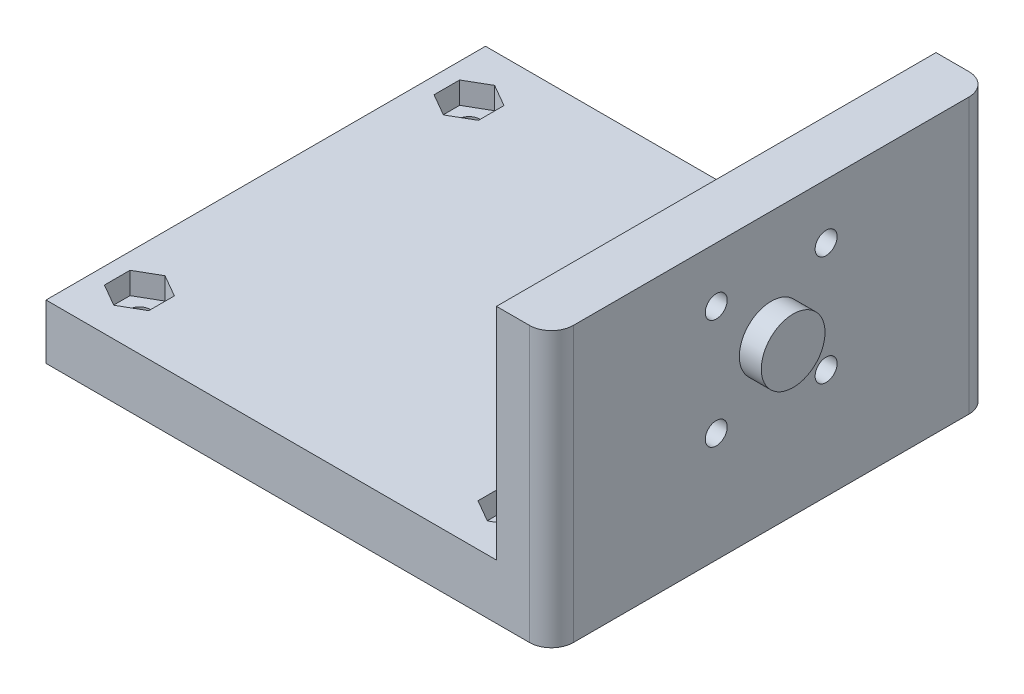
from build123d import *

# Parameters (mm, degrees)
ESQUISSE1_W             = 5
ESQUISSE1_H             = 40
BOSS_EXTRU_1_DEPTH      = 25
ESQUISSE2_W             = 40
ESQUISSE2_H             = 5
BOSS_EXTRU_2_DEPTH      = 41
CONG_1_R                = 2
ENL_V_MAT_EXTRU_1_REACH = 48
ESQUISSE4_R             = 1
ESQUISSE5_R             = 2.9
BOSS_EXTRU_3_DEPTH      = 2
ENL_V_MAT_EXTRU_3_DEPTH = 3
ESQUISSE9_R             = 1
ENL_V_MAT_EXTRU_5_DEPTH = 6
ENL_V_MAT_EXTRU_4_DEPTH = 2


with BuildPart() as part:
    # Esquisse1 → Boss.-Extru.1 (new body)
    with BuildSketch(Plane(origin=(0, 0, 0), x_dir=(1, 0, 0), z_dir=(0, 1, 0))):
        with Locations((-2.5, 0)):
            Rectangle(ESQUISSE1_W, ESQUISSE1_H)
    extrude(amount=-BOSS_EXTRU_1_DEPTH)

    # Esquisse2 → Boss.-Extru.2 (add)
    with BuildSketch(Plane.ZY.offset(5)):
        with Locations((0, -22.5)):
            Rectangle(ESQUISSE2_W, ESQUISSE2_H)
    extrude(amount=BOSS_EXTRU_2_DEPTH)

    # Congé1
    cong_1_edges = [part.edges().sort_by_distance(p)[0] for p in [
        (0, -12.5, 20),
        (0, -12.5, -20),
    ]]
    fillet(cong_1_edges, radius=CONG_1_R)

    # Esquisse4 → Enlèv. mat.-Extru.1 (cut, up to next)
    with BuildSketch(Plane(origin=(0, 0, 0), x_dir=(0, 0, -1), z_dir=(1, 0, 0)), mode=Mode.PRIVATE) as enl_v_mat_extru_1_sk1:
        with Locations((-5, -5)):
            Circle(ESQUISSE4_R)
    enl_v_mat_extru_1_tool1 = extrude(enl_v_mat_extru_1_sk1.sketch, amount=-ENL_V_MAT_EXTRU_1_REACH, mode=Mode.PRIVATE) & part.part
    add(enl_v_mat_extru_1_tool1.solids().sort_by_distance((0, -5, 5))[0], mode=Mode.SUBTRACT)
    # Esquisse4 → Enlèv. mat.-Extru.1 (cut, up to next)
    with BuildSketch(Plane(origin=(0, 0, 0), x_dir=(0, 0, -1), z_dir=(1, 0, 0)), mode=Mode.PRIVATE) as enl_v_mat_extru_1_sk2:
        with Locations((5, -5)):
            Circle(ESQUISSE4_R)
    enl_v_mat_extru_1_tool2 = extrude(enl_v_mat_extru_1_sk2.sketch, amount=-ENL_V_MAT_EXTRU_1_REACH, mode=Mode.PRIVATE) & part.part
    add(enl_v_mat_extru_1_tool2.solids().sort_by_distance((0, -5, -5))[0], mode=Mode.SUBTRACT)
    # Esquisse4 → Enlèv. mat.-Extru.1 (cut, up to next)
    with BuildSketch(Plane(origin=(0, 0, 0), x_dir=(0, 0, -1), z_dir=(1, 0, 0)), mode=Mode.PRIVATE) as enl_v_mat_extru_1_sk3:
        with Locations((-5, -15)):
            Circle(ESQUISSE4_R)
    enl_v_mat_extru_1_tool3 = extrude(enl_v_mat_extru_1_sk3.sketch, amount=-ENL_V_MAT_EXTRU_1_REACH, mode=Mode.PRIVATE) & part.part
    add(enl_v_mat_extru_1_tool3.solids().sort_by_distance((0, -15, 5))[0], mode=Mode.SUBTRACT)
    # Esquisse4 → Enlèv. mat.-Extru.1 (cut, up to next)
    with BuildSketch(Plane(origin=(0, 0, 0), x_dir=(0, 0, -1), z_dir=(1, 0, 0)), mode=Mode.PRIVATE) as enl_v_mat_extru_1_sk4:
        with Locations((5, -15)):
            Circle(ESQUISSE4_R)
    enl_v_mat_extru_1_tool4 = extrude(enl_v_mat_extru_1_sk4.sketch, amount=-ENL_V_MAT_EXTRU_1_REACH, mode=Mode.PRIVATE) & part.part
    add(enl_v_mat_extru_1_tool4.solids().sort_by_distance((0, -15, -5))[0], mode=Mode.SUBTRACT)

    # Esquisse5 → Boss.-Extru.3 (add)
    with BuildSketch(Plane(origin=(0, 0, 0), x_dir=(0, 0, -1), z_dir=(1, 0, 0))):
        with Locations((0, -10)):
            Circle(ESQUISSE5_R)
    extrude(amount=BOSS_EXTRU_3_DEPTH)

    # Esquisse7 → Enlèv. mat.-Extru.3 (cut)
    with BuildSketch(Plane.ZY.offset(5)):
        Polygon((-3.835, -7.017839191), (-2.67, -5), (-3.835, -2.982160809), (-6.165, -2.982160809), (-7.33, -5), (-6.165, -7.017839191), align=None)
        Polygon((3.835, -2.982160809), (2.67, -5), (3.835, -7.017839191), (6.165, -7.017839191), (7.33, -5), (6.165, -2.982160809), align=None)
        Polygon((-3.835, -17.017839191), (-2.67, -15), (-3.835, -12.982160809), (-6.165, -12.982160809), (-7.33, -15), (-6.165, -17.017839191), align=None)
        Polygon((7.33, -15), (6.165, -12.982160809), (3.835, -12.982160809), (2.67, -15), (3.835, -17.017839191), (6.165, -17.017839191), align=None)
    extrude(amount=-ENL_V_MAT_EXTRU_3_DEPTH, mode=Mode.SUBTRACT)

    # Esquisse9 → Enlèv. mat.-Extru.5 (cut, through all)
    with BuildSketch(Plane(origin=(0, -20, 0), x_dir=(1, 0, 0), z_dir=(0, 1, 0))):
        with Locations(Location((-8.5, 15, 0), (0, 0, 270))):  # turned: the seam where the file's is
            Circle(ESQUISSE9_R)
        with Locations(Location((-8.5, -15, 0), (0, 0, 270))):  # turned: the seam where the file's is
            Circle(ESQUISSE9_R)
        with Locations(Location((-42.5, -15, 0), (0, 0, 270))):  # turned: the seam where the file's is
            Circle(ESQUISSE9_R)
        with Locations(Location((-42.5, 15, 0), (0, 0, 270))):  # turned: the seam where the file's is
            Circle(ESQUISSE9_R)
    extrude(amount=-ENL_V_MAT_EXTRU_5_DEPTH, mode=Mode.SUBTRACT)

    # Esquisse8 → Enlèv. mat.-Extru.4 (cut)
    with BuildSketch(Plane(origin=(0, -20, 0), x_dir=(1, 0, 0), z_dir=(0, 1, 0))):
        Polygon((-10.517839191, 13.835), (-8.5, 12.67), (-6.482160809, 13.835), (-6.482160809, 16.165), (-8.5, 17.33), (-10.517839191, 16.165), align=None)
        Polygon((-10.517839191, -16.165), (-8.5, -17.33), (-6.482160809, -16.165), (-6.482160809, -13.835), (-8.5, -12.67), (-10.517839191, -13.835), align=None)
        Polygon((-44.517839191, -16.165), (-42.5, -17.33), (-40.482160809, -16.165), (-40.482160809, -13.835), (-42.5, -12.67), (-44.517839191, -13.835), align=None)
        Polygon((-42.5, 12.67), (-40.482160809, 13.835), (-40.482160809, 16.165), (-42.5, 17.33), (-44.517839191, 16.165), (-44.517839191, 13.835), align=None)
    extrude(amount=-ENL_V_MAT_EXTRU_4_DEPTH, mode=Mode.SUBTRACT)


solid = part.part
